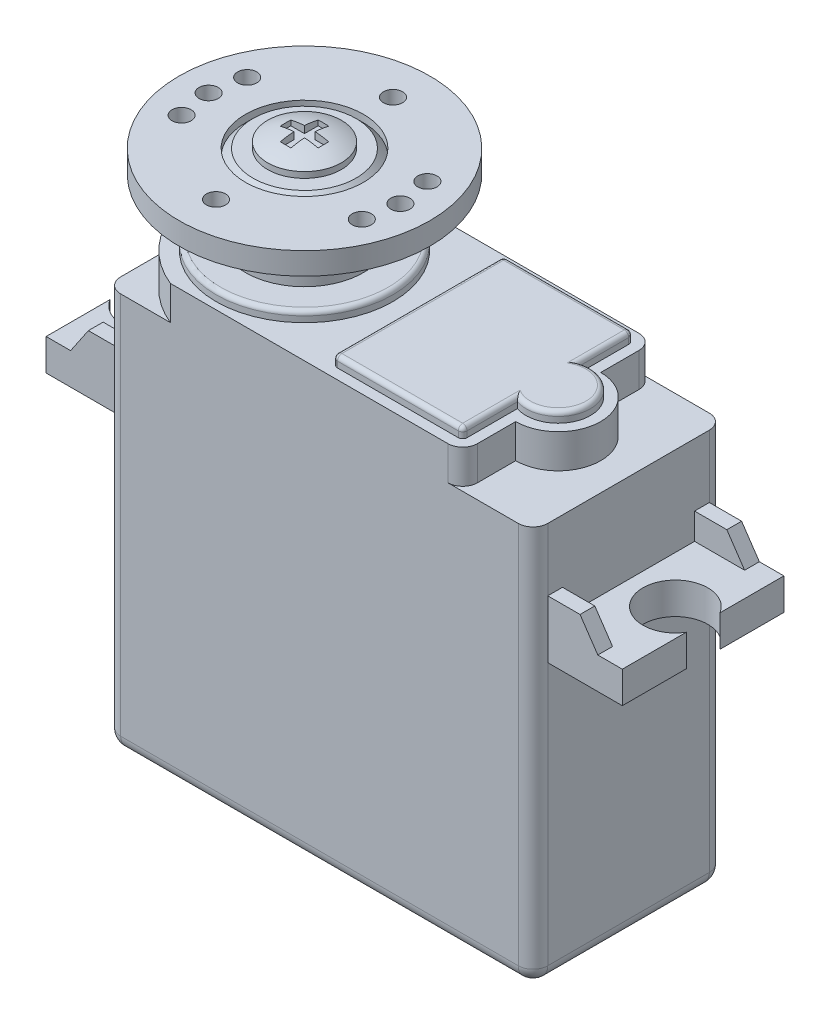
from build123d import *

# Parameters (mm, degrees)
SKETCH1_W                = 28.956
SKETCH1_H                = 26.972
BOSS_EXTRUDE1_DEPTH      = 6.477
BOSS_EXTRUDE1_DEPTH_BACK = 6.477
FILLET1_R                = 1
FILLET2_R                = 1
BOSS_EXTRUDE2_DEPTH      = 2.3
BOSS_EXTRUDE3_DEPTH      = 0.7
FILLET3_R                = 0.3
SKETCH5_R                = 6
BOSS_EXTRUDE4_DEPTH      = 0.7
FILLET4_R                = 0.3
SKETCH6_R                = 4
BOSS_EXTRUDE5_DEPTH      = 5.3
CHAMFER1_SIZE            = 0.5
SKETCH7_R                = 8.5
SKETCH7_R_2              = 4
BOSS_EXTRUDE6_DEPTH      = 1.5
SKETCH8_R                = 0.65
CUT_EXTRUDE1_DEPTH       = 1.5
SKETCH9_R                = 0.65
CUT_EXTRUDE2_DEPTH       = 1.5
CIRPATTERN1_COUNT        = 2
CIRPATTERN1_ANGLE        = 20
CIRPATTERN2_COUNT        = 2
CIRPATTERN2_ANGLE        = 20
CUT_EXTRUDE3_DEPTH       = 0.5
BOSS_EXTRUDE7_DEPTH      = 5.477
BOSS_EXTRUDE7_DEPTH_BACK = 5.477
SKETCH16_W               = 8.954
SKETCH16_H               = 4.011652596
CUT_EXTRUDE4_DEPTH       = 5.055762
SKETCH17_W               = 8.954
SKETCH17_H               = 3.380527785
CUT_EXTRUDE5_DEPTH       = 5.055762
SKETCH18_R               = 2.2
CUT_EXTRUDE6_DEPTH       = 21.941804104


with BuildPart() as part:
    # Sketch1 → Boss-Extrude1 (new body, two sides)
    with BuildSketch(Plane.XY) as boss_extrude1_sk:
        with Locations((0, 0.702144992)):
            Rectangle(SKETCH1_W, SKETCH1_H)
    extrude(amount=BOSS_EXTRUDE1_DEPTH)
    extrude(boss_extrude1_sk.sketch, amount=-BOSS_EXTRUDE1_DEPTH_BACK)

    # Fillet1
    fillet1_edges = [part.edges().sort_by_distance(p)[0] for p in [
        (14.478, 0.702144992, -6.477),
        (-14.478, 0.702144992, 6.477),
        (14.478, 0.702144992, 6.477),
        (-14.478, 0.702144992, -6.477),
    ]]
    fillet(fillet1_edges, radius=FILLET1_R)

    # Fillet2
    fillet2_edges = [part.edges().sort_by_distance(p)[0] for p in [
        (14.478, -12.783855008, 0),
        (0, -12.783855008, -6.477),
        (0, -12.783855008, 6.477),
        (-14.478, -12.783855008, 0),
        (-14.185106781, -12.783855008, 6.184106781),
        (-14.185106781, -12.783855008, -6.184106781),
        (14.185106781, -12.783855008, 6.184106781),
        (14.185106781, -12.783855008, -6.184106781),
    ]]
    fillet(fillet2_edges, radius=FILLET2_R)

    # Sketch3 → Boss-Extrude2 (add)
    with BuildSketch(Plane(origin=(0, 14.188144992, 0), x_dir=(1, 0, 0), z_dir=(0, 1, 0))):
        with BuildLine():
            Line((-10.109849088, 6.477), (8.710547639, 6.477))
            ThreePointArc((8.710547639, 6.477), (9.41765442, 6.184106781), (9.710547639, 5.477))
            Line((9.710547639, 5.477), (9.710547639, 2.882503788))
            ThreePointArc((9.710547639, 2.882503788), (12.593051427, 0), (9.710547639, -2.882503788))
            Line((9.710547639, -2.882503788), (9.710547639, -5.477))
            ThreePointArc((9.710547639, -5.477), (9.41765442, -6.184106781), (8.710547639, -6.477))
            Line((8.710547639, -6.477), (-10.109849088, -6.477))
            ThreePointArc((-10.109849088, -6.477), (-14.478, 0), (-10.109849088, 6.477))
        make_face()
    extrude(amount=BOSS_EXTRUDE2_DEPTH)

    # Sketch4 → Boss-Extrude3 (add)
    with BuildSketch(Plane(origin=(0, 16.488144992, 0), x_dir=(1, 0, 0), z_dir=(0, 1, 0))):
        with BuildLine():
            Line((9.010547639, 2.06720168), (9.010547639, 5.477))
            ThreePointArc((9.010547639, 5.477), (8.922679673, 5.689132034), (8.710547639, 5.777))
            Line((8.710547639, 5.777), (0.524279087, 5.777))
            ThreePointArc((0.524279087, 5.777), (0.312147052, 5.689132034), (0.224279087, 5.477))
            Line((0.224279087, 5.477), (0.224279087, -5.477))
            ThreePointArc((0.224279087, -5.477), (0.312147052, -5.689132034), (0.524279087, -5.777))
            Line((0.524279087, -5.777), (8.710547639, -5.777))
            ThreePointArc((8.710547639, -5.777), (8.922679673, -5.689132034), (9.010547639, -5.477))
            Line((9.010547639, -5.477), (9.010547639, -2.06720168))
            ThreePointArc((9.010547639, -2.06720168), (11.893051427, 0), (9.010547639, 2.06720168))
        make_face()
    extrude(amount=BOSS_EXTRUDE3_DEPTH)

    # Fillet3
    fillet3_edges = [part.edges().sort_by_distance(p)[0] for p in [
        (11.893051427, 17.188144992, 0),
        (9.010547639, 17.188144992, -3.77210084),
        (8.922679673, 17.188144992, -5.689132034),
        (4.617413363, 17.188144992, -5.777),
        (0.312147052, 17.188144992, -5.689132034),
        (0.224279087, 17.188144992, 0),
        (0.312147052, 17.188144992, 5.689132034),
        (4.617413363, 17.188144992, 5.777),
        (8.922679673, 17.188144992, 5.689132034),
        (9.010547639, 17.188144992, 3.77210084),
    ]]
    fillet(fillet3_edges, radius=FILLET3_R)

    # Sketch5 → Boss-Extrude4 (add)
    with BuildSketch(Plane(origin=(0, 16.488144992, 0), x_dir=(1, 0, 0), z_dir=(0, 1, 0))):
        with Locations((-7.491946563, 0)):
            Circle(SKETCH5_R)
    extrude(amount=BOSS_EXTRUDE4_DEPTH)

    # Fillet4
    fillet4_edges = [part.edges().sort_by_distance(p)[0] for p in [
        (-13.491946563, 17.188144992, 0),
    ]]
    fillet(fillet4_edges, radius=FILLET4_R)

    # Sketch6 → Boss-Extrude5 (add)
    with BuildSketch(Plane(origin=(0, 17.188144992, 0), x_dir=(1, 0, 0), z_dir=(0, 1, 0))):
        with Locations((-7.491946563, 0)):
            Circle(SKETCH6_R)
    extrude(amount=BOSS_EXTRUDE5_DEPTH)

    # Chamfer1
    chamfer1_edges = [part.edges().sort_by_distance(p)[0] for p in [
        (-11.491946563, 22.488144992, 0),
    ]]
    chamfer(chamfer1_edges, length=CHAMFER1_SIZE)

    # Sketch7 → Boss-Extrude6 (add)
    with BuildSketch(Plane(origin=(0, 22.488144992, 0), x_dir=(1, 0, 0), z_dir=(0, 1, 0))):
        with Locations((-7.491946563, 0)):
            Circle(SKETCH7_R)
        with Locations((-7.491946563, 0)):
            Circle(SKETCH7_R_2, mode=Mode.SUBTRACT)
    extrude(amount=-BOSS_EXTRUDE6_DEPTH)

    # Sketch8 → Cut-Extrude1 (cut)
    with BuildSketch(Plane(origin=(0, 22.488144992, 0), x_dir=(1, 0, 0), z_dir=(0, 1, 0))):
        with Locations((-7.491946563, -6)):
            Circle(SKETCH8_R)
        with Locations((-7.491946563, 6)):
            Circle(SKETCH8_R)
    extrude(amount=-CUT_EXTRUDE1_DEPTH, mode=Mode.SUBTRACT)

    # Sketch9 → Cut-Extrude2 (cut)
    with BuildSketch(Plane(origin=(0, 22.488144992, 0), x_dir=(1, 0, 0), z_dir=(0, 1, 0))):
        with Locations((-13.991946563, 0)):
            Circle(SKETCH9_R)
        with Locations((-0.991946563, 0)):
            Circle(SKETCH9_R)
    cut_extrude2 = extrude(amount=-CUT_EXTRUDE2_DEPTH, mode=Mode.SUBTRACT)

    # CirPattern1: Cut-Extrude2 ×2 about axis
    cirpattern1_axis = Axis((-7.491946563, 0, 0), (0, 1, 0))
    for i in range(1, CIRPATTERN1_COUNT):
        add(cut_extrude2.rotate(cirpattern1_axis, i * CIRPATTERN1_ANGLE / (CIRPATTERN1_COUNT - 1)), mode=Mode.SUBTRACT)

    # CirPattern2: Cut-Extrude2 ×2 about axis
    cirpattern2_axis = Axis((-7.491946563, 0, 0), (0, -1, 0))
    for i in range(1, CIRPATTERN2_COUNT):
        add(cut_extrude2.rotate(cirpattern2_axis, i * CIRPATTERN2_ANGLE / (CIRPATTERN2_COUNT - 1)), mode=Mode.SUBTRACT)

    # Sketch11 → Revolve1 (revolve)
    with BuildSketch(Plane.XY):
        with BuildLine():
            Line((-4.991946563, 22.488144992), (-4.991946563, 22.888144992))
            add(Edge.make_bspline(
                [(-4.991946563, 22.888144992), (-6.158337638, 23.488144992), (-7.491946563, 23.488144992)],
                knots=[0, 0, 0, 1, 1, 1], degree=2))
            Line((-7.491946563, 23.488144992), (-7.491946563, 22.488144992))
            Line((-7.491946563, 22.488144992), (-4.991946563, 22.488144992))
        make_face()
    revolve(axis=Axis((-7.491946563, 22.488144992, 0), (0, 1, 0)))

    # Sketch12 → Cut-Extrude3 (cut)
    with BuildSketch(Plane(origin=(0, 23.488144992, 0), x_dir=(1, 0, 0), z_dir=(0, 1, 0))):
        Polygon((-7.131090135, -1.285309656), (-7.131090135, -0.360856428), (-6.206636907, -0.360856428), (-6.206636907, 0.360856428), (-7.131090135, 0.360856428), (-7.131090135, 1.285309656), (-7.85280299, 1.285309656), (-7.85280299, 0.360856428), (-8.777256218, 0.360856428), (-8.777256218, -0.360856428), (-7.85280299, -0.360856428), (-7.85280299, -1.285309656), align=None)
    extrude(amount=-CUT_EXTRUDE3_DEPTH, mode=Mode.SUBTRACT)

    # Sketch14 → Boss-Extrude7 (add, two sides)
    with BuildSketch(Plane.XY) as boss_extrude7_sk:
        Polygon((-14.478, 6.012144992), (-19.53376211, 6.012144992), (-19.53376211, 8.157949096), (-17.871474894, 8.157949096), (-16.666917549, 9.936604913), (-14.478, 9.936604913), align=None)
        Polygon((19.53376211, 6.012144992), (19.53376211, 8.157949096), (17.871474894, 8.157949096), (16.666917549, 9.936604913), (14.478, 9.936604913), (14.478, 6.012144992), align=None)
    extrude(amount=BOSS_EXTRUDE7_DEPTH)
    extrude(boss_extrude7_sk.sketch, amount=-BOSS_EXTRUDE7_DEPTH_BACK)

    # Sketch16 → Cut-Extrude4 (cut)
    with BuildSketch(Plane.ZY.offset(19.53376211)):
        with Locations((0, 10.163775394)):
            Rectangle(SKETCH16_W, SKETCH16_H)
    extrude(amount=-CUT_EXTRUDE4_DEPTH, mode=Mode.SUBTRACT)

    # Sketch17 → Cut-Extrude5 (cut)
    with BuildSketch(Plane(origin=(19.53376211, 0, 0), x_dir=(0, 0, -1), z_dir=(1, 0, 0))):
        with Locations((0, 9.848212989)):
            Rectangle(SKETCH17_W, SKETCH17_H)
    extrude(amount=-CUT_EXTRUDE5_DEPTH, mode=Mode.SUBTRACT)

    # Sketch18 → Cut-Extrude6 (cut, through all)
    with BuildSketch(Plane(origin=(0, 8.157949096, 0), x_dir=(1, 0, 0), z_dir=(0, 1, 0))):
        with Locations((17.653, 0)):
            Circle(SKETCH18_R)
        with Locations((-17.653, 0)):
            Circle(SKETCH18_R)
    extrude(amount=-CUT_EXTRUDE6_DEPTH, mode=Mode.SUBTRACT)


solid = part.part
